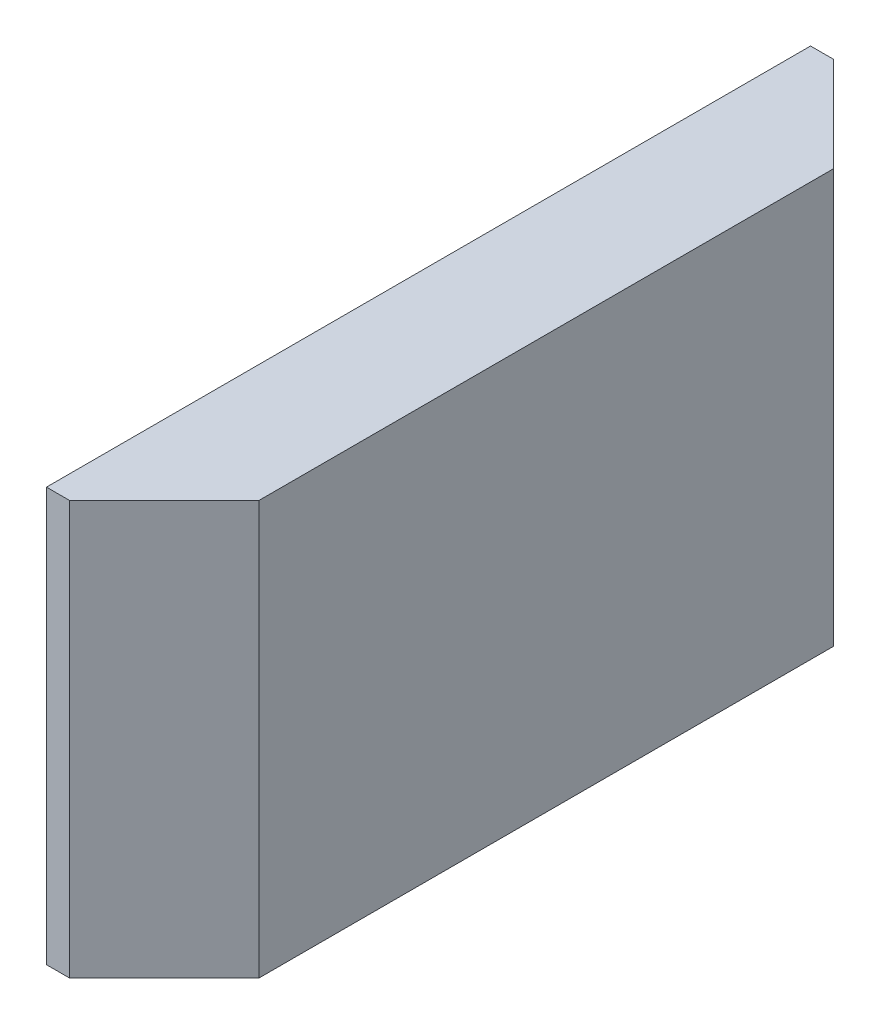
from build123d import *

# Parameters (mm, degrees)
BOSS_EXTRUDE1_DEPTH = 144


with BuildPart() as part:
    # Sketch1 → Boss-Extrude1 (new body)
    with BuildSketch(Plane(origin=(0, 0, 0), x_dir=(1, 0, 0), z_dir=(0, 1, 0))):
        Polygon((0, -100), (-33, -133), (-41, -133), (-41, 133), (-33, 133), (0, 100), align=None)
    extrude(amount=BOSS_EXTRUDE1_DEPTH)


solid = part.part
